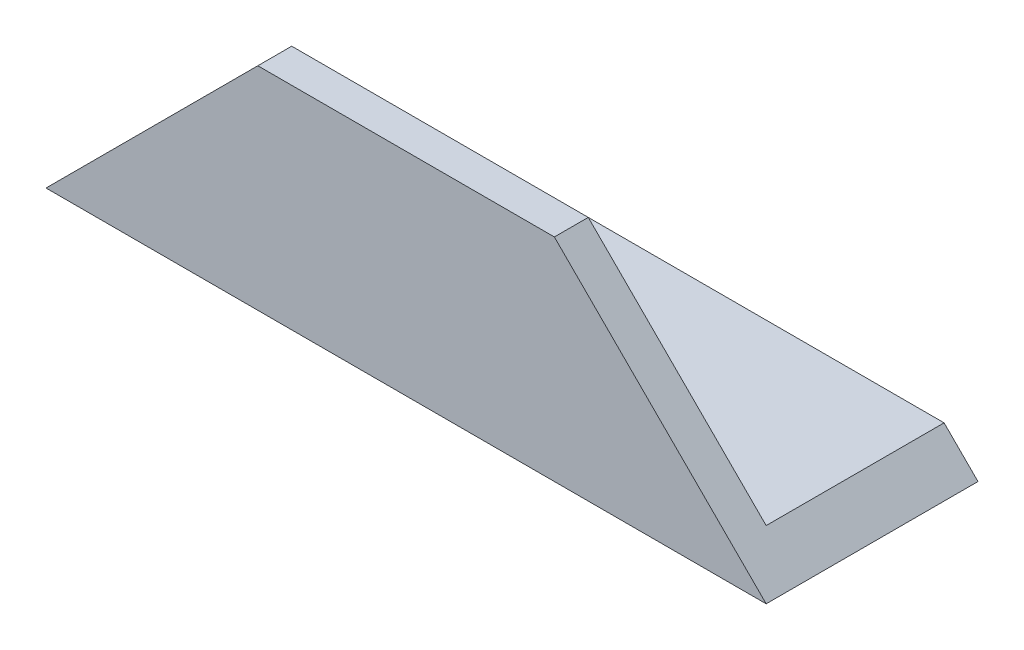
from build123d import *

# Parameters (mm, degrees)
EXTRUDE_1_DEPTH     = 85
CUT_EXTRUDE_1_DEPTH = 26
SKETCH_3_W          = 32
SKETCH_3_H          = 21
CUT_EXTRUDE_2_DEPTH = 10


with BuildPart() as part:
    # Эскиз1 → Вытянуть-Тонкостенный1 (new body)
    with BuildSketch(Plane(origin=(0, 0, 0), x_dir=(0, 0, -1), z_dir=(1, 0, 0))):
        Polygon((0, 25), (0, 0), (25, 0), (25, 4), (4, 4), (4, 25), align=None)
    extrude(amount=EXTRUDE_1_DEPTH)

    # Эскиз2 → Вырез-Вытянуть1 (cut, through all)
    with BuildSketch(Plane.XY):
        Polygon((0, 0), (0, 25), (25, 25), align=None)
        Polygon((60, 25), (85, 25), (85, 0), align=None)
    extrude(amount=-CUT_EXTRUDE_1_DEPTH, mode=Mode.SUBTRACT)

    # Эскиз3 → Вырез-Вытянуть2 (cut)
    with BuildSketch(Plane.XZ):
        with Locations((16, -14.5)):
            Rectangle(SKETCH_3_W, SKETCH_3_H)
    extrude(amount=-CUT_EXTRUDE_2_DEPTH, mode=Mode.SUBTRACT)


solid = part.part
